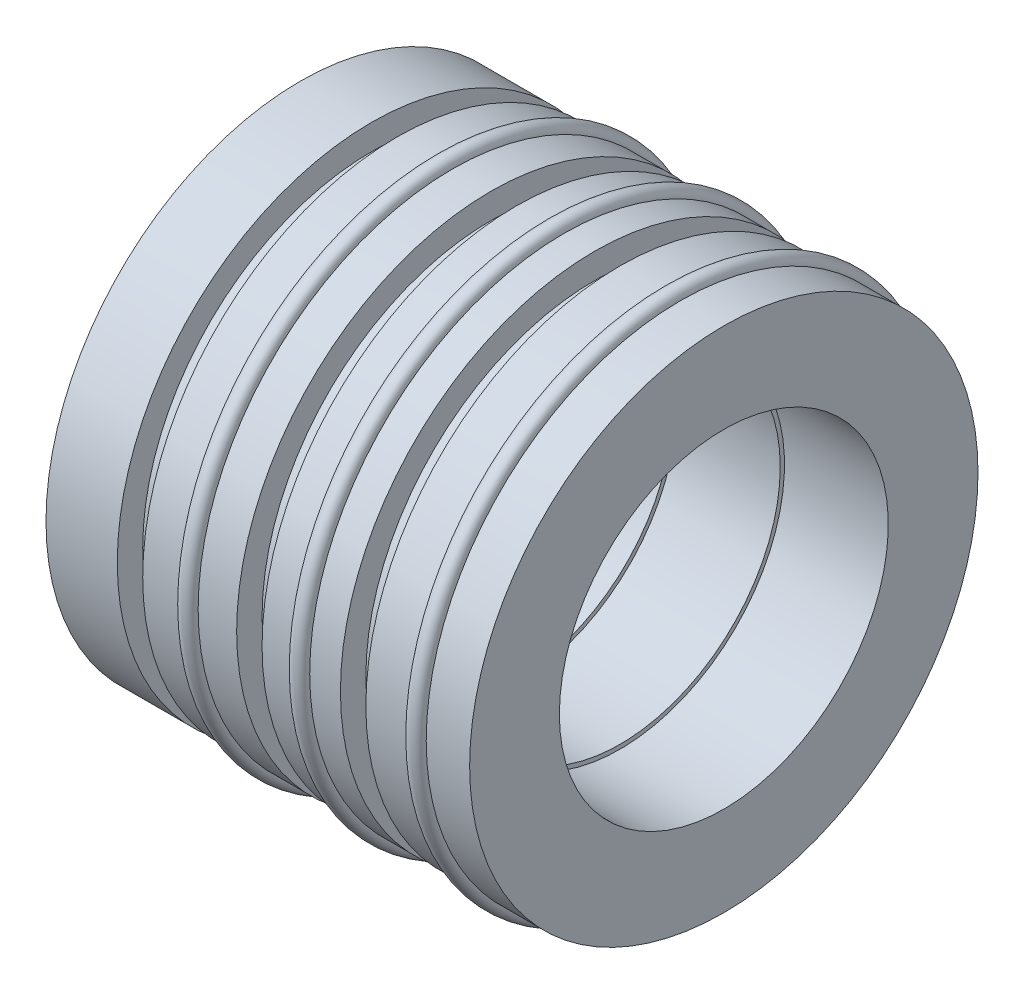
from build123d import *


with BuildPart() as part:
    # Sketch1 → Revolve1 (revolve)
    with BuildSketch(Plane.XY):
        with BuildLine():
            Line((6.377996837, 9.352788), (6.377996837, 15.24))
            Line((6.377996837, 15.24), (10.652236324, 15.24))
            Line((10.652236324, 15.24), (10.652236324, 13.716))
            Line((10.652236324, 13.716), (12.176236324, 13.716))
            Line((12.176236324, 13.716), (12.176236324, 15.24))
            Line((12.176236324, 15.24), (14.484116581, 15.24))
            ThreePointArc((14.484116581, 15.24), (14.992116581, 15.748), (15.500116581, 15.24))
            Line((15.500116581, 15.24), (17.807996837, 15.24))
            Line((17.807996837, 15.24), (17.807996837, 13.716))
            Line((17.807996837, 13.716), (19.331996837, 13.716))
            Line((19.331996837, 13.716), (19.331996837, 15.24))
            Line((19.331996837, 15.24), (21.173496837, 15.24))
            ThreePointArc((21.173496837, 15.24), (21.681496837, 15.748), (22.189496837, 15.24))
            Line((22.189496837, 15.24), (24.030996837, 15.24))
            Line((24.030996837, 15.24), (24.030996837, 13.716))
            Line((24.030996837, 13.716), (25.554996837, 13.716))
            Line((25.554996837, 13.716), (25.554996837, 15.24))
            Line((25.554996837, 15.24), (28.158496837, 15.24))
            ThreePointArc((28.158496837, 15.24), (28.666496837, 15.748), (29.174496837, 15.24))
            Line((29.174496837, 15.24), (31.777996837, 15.24))
            Line((31.777996837, 15.24), (31.777996837, 9.860788))
            Line((31.777996837, 9.860788), (25.554996837, 9.860788))
            Line((25.554996837, 9.860788), (25.554996837, 9.606788))
            Line((25.554996837, 9.606788), (19.331996837, 9.606788))
            Line((19.331996837, 9.606788), (19.331996837, 9.352788))
            Line((19.331996837, 9.352788), (13.108996837, 9.352788))
            Line((13.108996837, 9.352788), (6.377996837, 9.352788))
        make_face()
    revolve(axis=Axis((0, 0, 0), (1, 0, 0)))


solid = part.part
